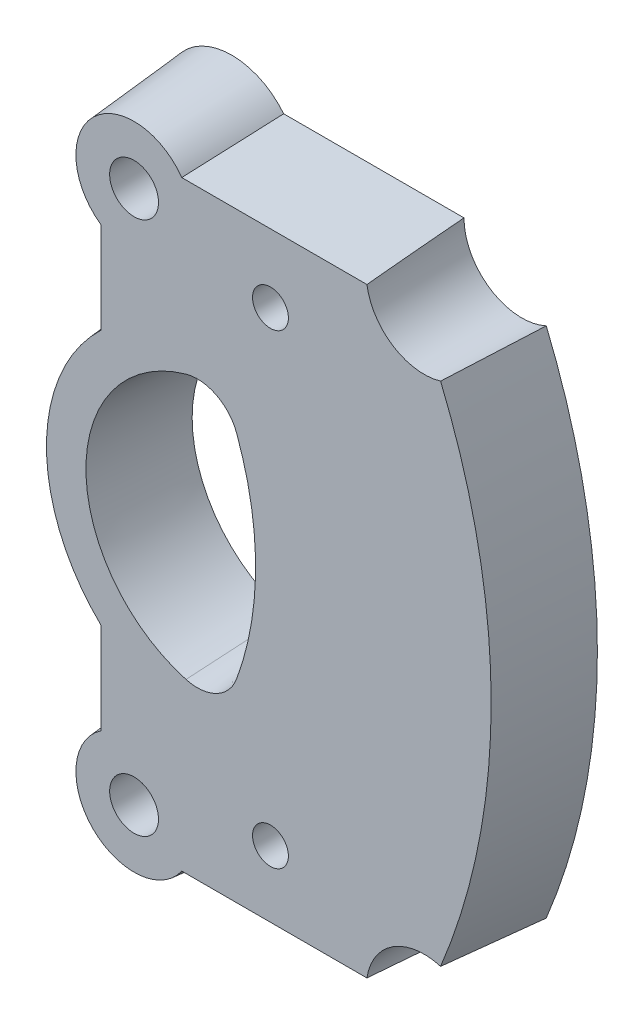
from build123d import *

# Parameters (mm, degrees)
EXTRUDE1_DEPTH     = 17.78
EXTRUDE1_DRAFT     = 5
SKETCH3_R          = 4.445
CUT_EXTRUDE2_DEPTH = 18.78
CUT_EXTRUDE3_DEPTH = 18.78
CUT_EXTRUDE3_TAPER = 5
SKETCH5_R          = 10.522638874
CUT_EXTRUDE4_DEPTH = 26.162
SKETCH6_R          = 3.2639
CUT_EXTRUDE5_DEPTH = 7.62


with BuildPart() as part:
    # Sketch1 → Extrude1 (with draft: the straight prism first)
    with BuildSketch(Plane.XY):
        with BuildLine():
            ThreePointArc((-195.012025381, 26.062859944), (-204.895443331, 2.202178287), (-195.012025381, -21.658503371))
            Line((-195.012025381, -21.658503371), (-195.012025381, -36.94271364))
            ThreePointArc((-195.012025381, -36.94271364), (-195.978739559, -54.984528068), (-177.936925131, -54.017813891))
            Line((-177.936925131, -54.017813891), (-134.591688961, -54.017813891))
            ThreePointArc((-134.591688961, -54.017813891), (-120.832429722, 2.202178287), (-134.591688961, 58.422170464))
            Line((-134.591688961, 58.422170464), (-177.936925131, 58.422170464))
            ThreePointArc((-177.936925131, 58.422170464), (-195.978739559, 59.388884642), (-195.012025381, 41.347070214))
            Line((-195.012025381, 41.347070214), (-195.012025381, 26.062859944))
        make_face()
    extrude(amount=EXTRUDE1_DEPTH)
    # Extrude1: the draft: its side faces are tilted about the plane it starts from
    extrude1_sides = [part.faces().sort_by_distance(p)[0] for p in [
        (-204.895443331, 2.202178287, 8.89),
        (-195.012025381, -29.300608506, 8.89),
        (-195.978739559, -54.984528068, 8.89),
        (-156.264307046, -54.017813891, 8.89),
        (-120.832429722, 2.202178287, 8.89),
        (-156.264307046, 58.422170464, 8.89),
        (-195.978739559, 59.388884642, 8.89),
        (-195.012025381, 33.704965079, 8.89),
    ]]
    draft(extrude1_sides, Plane.XY, EXTRUDE1_DRAFT)

    # Sketch3 → Cut-Extrude2 (cut, through all)
    with BuildSketch(Plane(origin=(10.378673568, 21.507111235, 17.78), x_dir=(1, 0, 0), z_dir=(0, 0, 1))):
        with Locations((-197.770698949, 29.295059229)):
            Circle(SKETCH3_R)
        with Locations((-197.770698949, -67.904925126)):
            Circle(SKETCH3_R)
    extrude(amount=-CUT_EXTRUDE2_DEPTH, mode=Mode.SUBTRACT)

    # Sketch4 → Cut-Extrude3 (cut, through all)
    with BuildSketch(Plane.XY.offset(17.78)):
        with BuildLine():
            ThreePointArc((-177.936489958, 26.267275972), (-196.154686221, 2.202178287), (-177.936489958, -21.862919399))
            ThreePointArc((-177.936489958, -21.862919399), (-172.405947357, -21.316646023), (-168.71726973, -17.159847564))
            ThreePointArc((-168.71726973, -17.159847564), (-165.268623085, 2.202178287), (-168.71726973, 21.564204137))
            ThreePointArc((-168.71726973, 21.564204137), (-172.405947357, 25.721002597), (-177.936489958, 26.267275972))
        make_face()
    extrude(amount=-CUT_EXTRUDE3_DEPTH, taper=CUT_EXTRUDE3_TAPER, mode=Mode.SUBTRACT)

    # Sketch5 → Cut-Extrude4 (cut)
    with BuildSketch(Plane(origin=(0, 0, 0), x_dir=(-1, 0, 0), z_dir=(0, 0, -1))):
        with Locations((134.591688961, 58.422170464)):
            Circle(SKETCH5_R)
        with Locations((134.591688961, -54.017813891)):
            Circle(SKETCH5_R)
    extrude(amount=-CUT_EXTRUDE4_DEPTH, mode=Mode.SUBTRACT)

    # Sketch6 → Cut-Extrude5 (cut)
    with BuildSketch(Plane.XY.offset(17.78)):
        with Locations((-162.563054604, 44.430433633)):
            Circle(SKETCH6_R)
        with Locations((-162.563054604, -40.394882783)):
            Circle(SKETCH6_R)
    extrude(amount=-CUT_EXTRUDE5_DEPTH, mode=Mode.SUBTRACT)


solid = part.part
